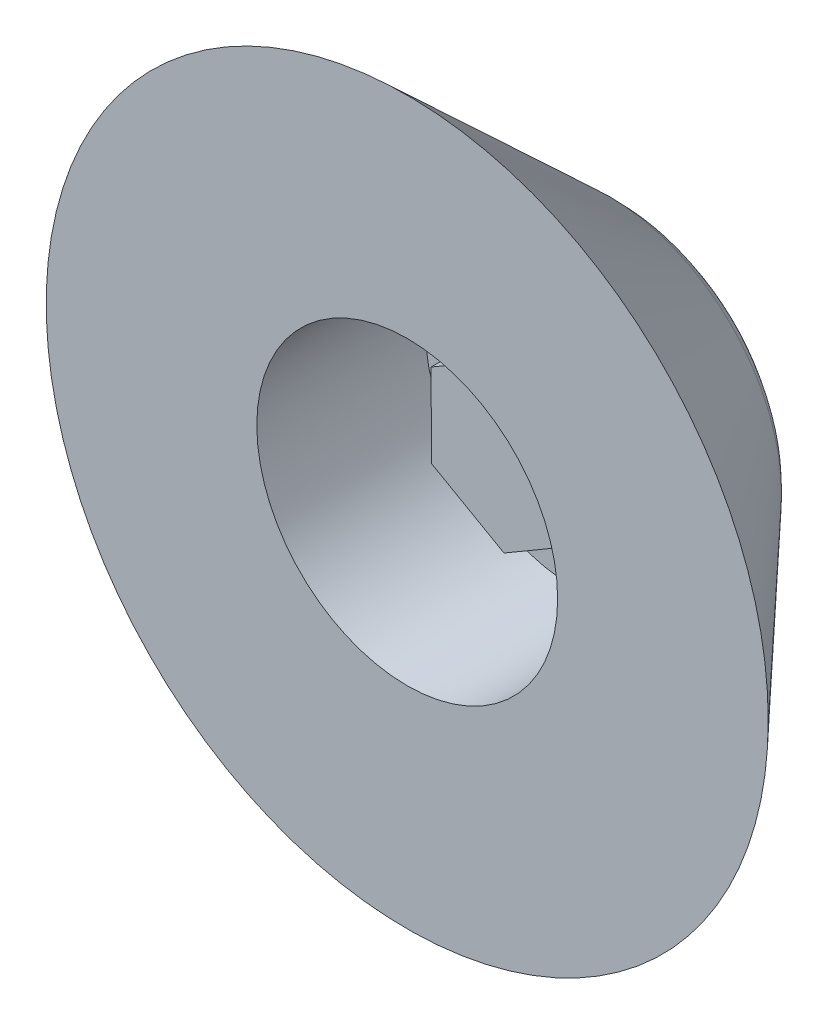
from build123d import *

# Parameters (mm, degrees)
SKETCH2_R          = 6.25
CUT_EXTRUDE1_DEPTH = 7
CUT_EXTRUDE2_DEPTH = 4
FILLET1_R          = 5


with BuildPart() as part:
    # Sketch1 → Revolve1 (revolve)
    with BuildSketch(Plane(origin=(0, 0, 0), x_dir=(1, 0, 0), z_dir=(0, 1, 0))):
        Polygon((0, 0), (0, 10), (5.659340659, 10), (15, 0), align=None)
    revolve(axis=Axis((0, 0, 0), (0, 0, -1)))

    # Sketch2 → Cut-Extrude1 (cut)
    with BuildSketch(Plane.XY):
        Circle(SKETCH2_R)
        Polygon((2.989454216, 1.750189559), (-0.020981512, 3.464038074), (-3.010435727, 1.713848515), (-2.989454216, -1.750189559), (0.020981512, -3.464038074), (3.010435727, -1.713848515), align=None, mode=Mode.SUBTRACT)
    extrude(amount=-CUT_EXTRUDE1_DEPTH, mode=Mode.SUBTRACT)

    # Sketch4 → Cut-Extrude2 (cut)
    with BuildSketch(Plane.XY):
        Polygon((-0.020981512, 3.464038074), (-3.010435727, 1.713848515), (-2.989454216, -1.750189559), (0.020981512, -3.464038074), (3.010435727, -1.713848515), (2.989454216, 1.750189559), align=None)
    extrude(amount=-CUT_EXTRUDE2_DEPTH, mode=Mode.SUBTRACT)

    # Fillet1
    fillet1_edges = [part.edges().sort_by_distance(p)[0] for p in [
        (-5.659340659, 0, -10),
    ]]
    fillet(fillet1_edges, radius=FILLET1_R)


solid = part.part
